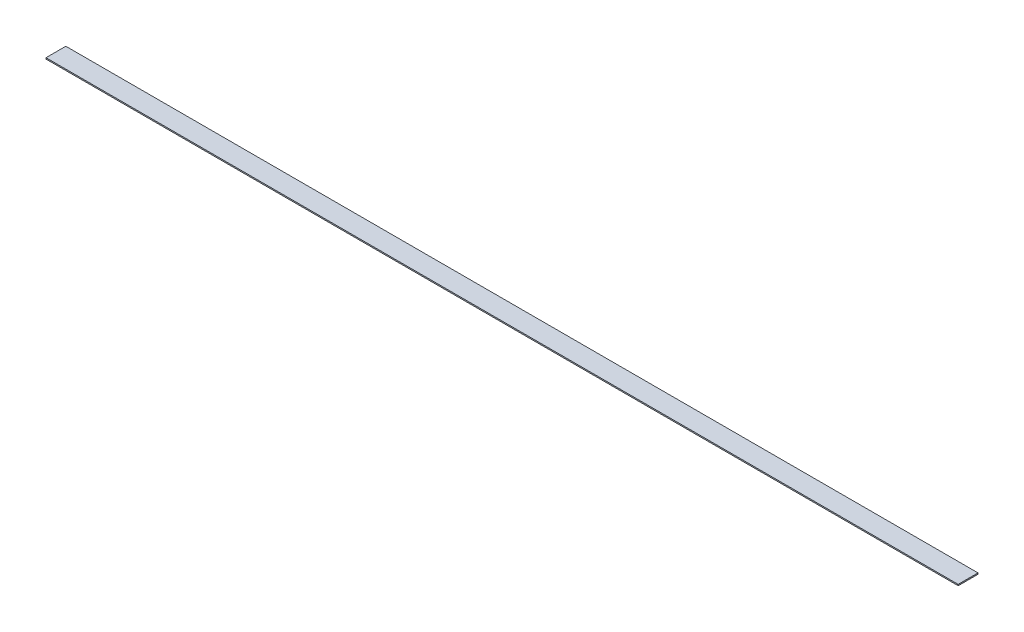
from build123d import *

# Parameters (mm, degrees)
SKETCH1_W           = 1168.4
SKETCH1_H           = 25.4
BOSS_EXTRUDE1_DEPTH = 1.5875


with BuildPart() as part:
    # Sketch1 → Boss-Extrude1 (new body)
    with BuildSketch(Plane(origin=(0, 0, 0), x_dir=(1, 0, 0), z_dir=(0, 1, 0))):
        Rectangle(SKETCH1_W, SKETCH1_H)
    extrude(amount=BOSS_EXTRUDE1_DEPTH)


solid = part.part
